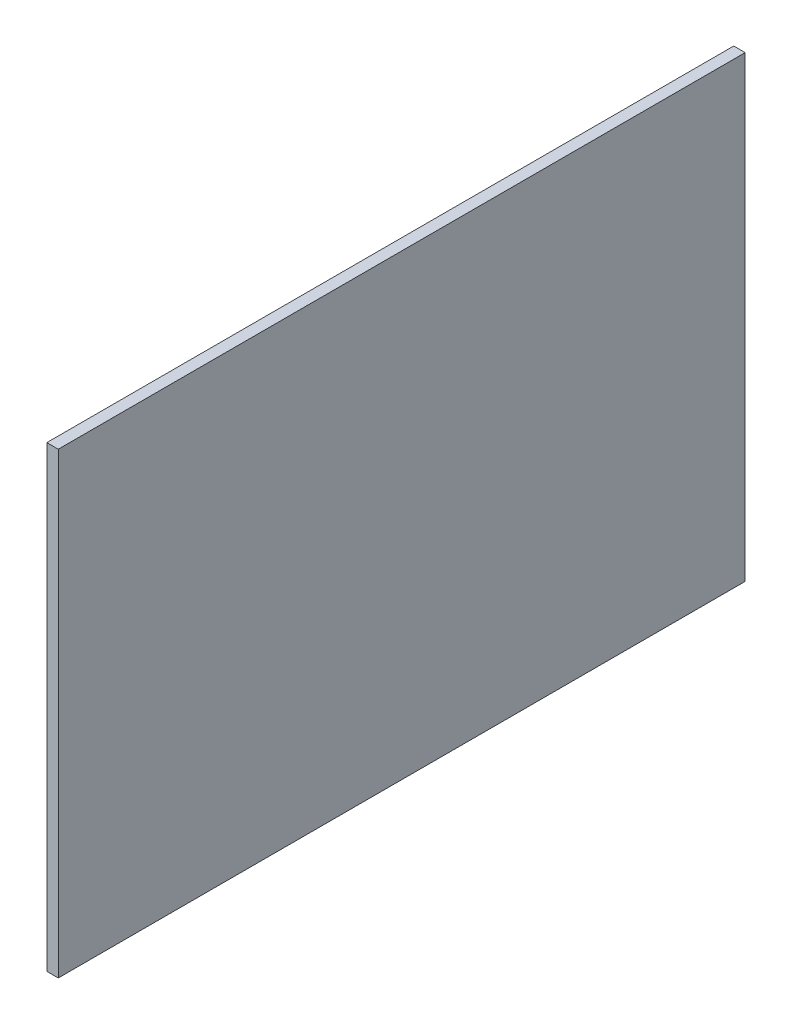
from build123d import *

# Parameters (mm, degrees)
SKETCH1_W           = 600
SKETCH1_H           = 400
BOSS_EXTRUDE1_DEPTH = 10


with BuildPart() as part:
    # Sketch1 → Boss-Extrude1 (new body)
    with BuildSketch(Plane(origin=(-5292.430568563, 3271.853201216, 87.343483914), x_dir=(0, 0, -1), z_dir=(1, 0, 0))):
        with Locations((-1268.346184082, 278.718754864)):
            Rectangle(SKETCH1_W, SKETCH1_H)
    extrude(amount=BOSS_EXTRUDE1_DEPTH)


solid = part.part
